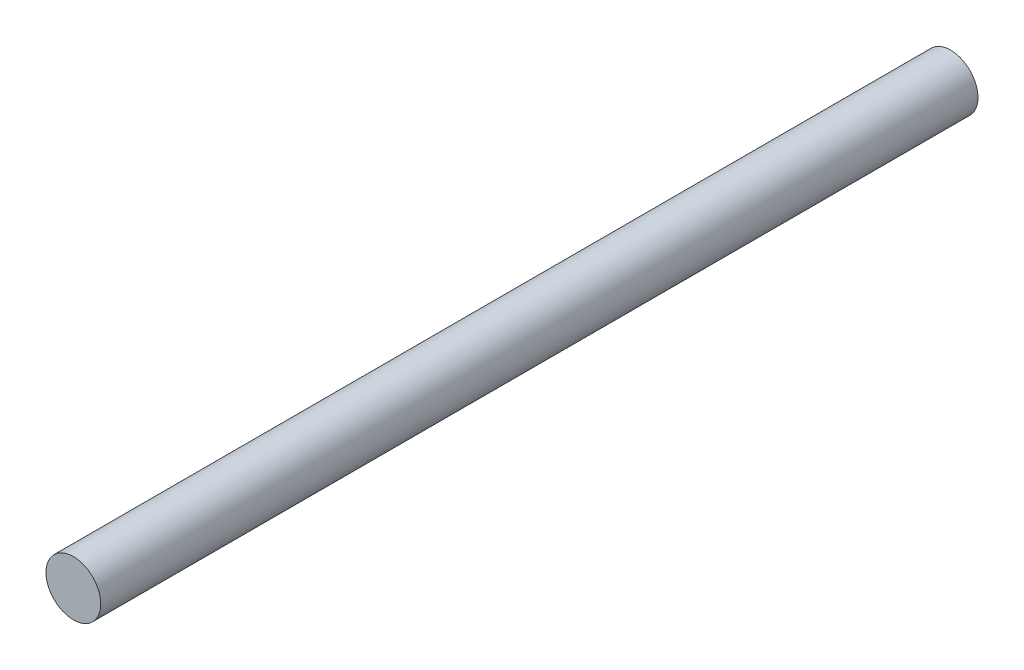
from build123d import *

# Parameters (mm, degrees)
SKETCH1_R           = 2.38125
BOSS_EXTRUDE1_DEPTH = 76.2


with BuildPart() as part:
    # Sketch1 → Boss-Extrude1 (new body)
    with BuildSketch(Plane.XY):
        Circle(SKETCH1_R)
    extrude(amount=BOSS_EXTRUDE1_DEPTH)


solid = part.part
